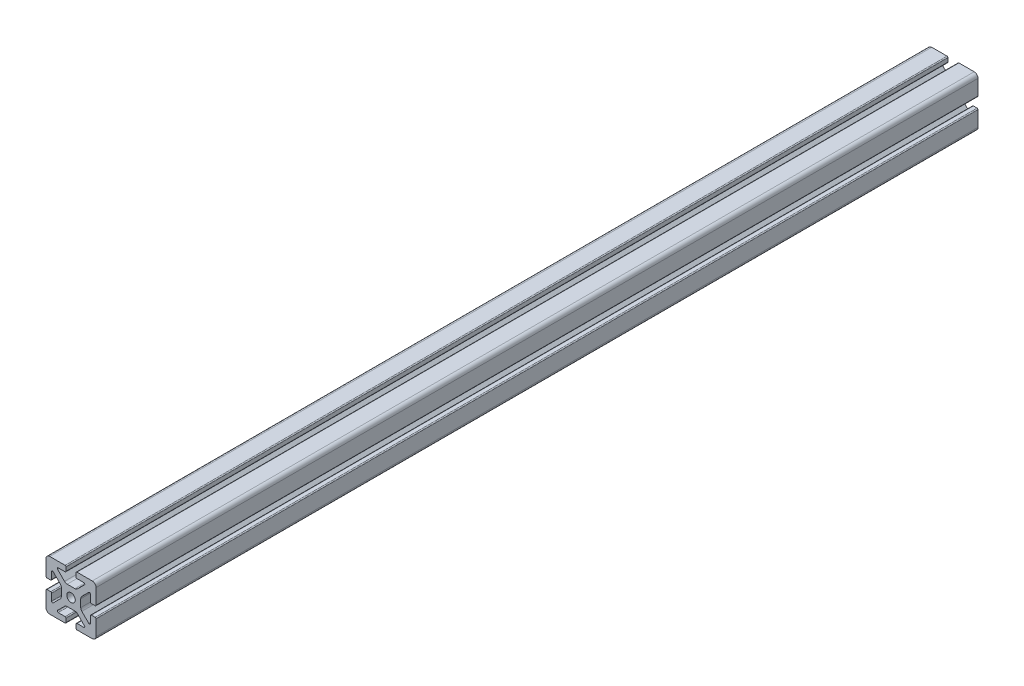
from build123d import *

# Parameters (mm, degrees)
SKETCH1_R           = 3.4036
BOSS_EXTRUDE1_DEPTH = 352.5


with BuildPart() as part:
    # Sketch1 → Boss-Extrude1 (new body, symmetric)
    with BuildSketch(Plane.XY):
        with BuildLine():
            Line((-20, 16.952), (-20, 4.7625))
            ThreePointArc((-20, 4.7625), (-19.776815367, 4.223684633), (-19.238, 4.0005))
            Line((-19.238, 4.0005), (-16.2662, 4.0005))
            ThreePointArc((-16.2662, 4.0005), (-15.727384633, 4.223684633), (-15.5042, 4.7625))
            Line((-15.5042, 4.7625), (-15.5042, 10.2235))
            ThreePointArc((-15.5042, 10.2235), (-15.033804775, 10.927496204), (-14.203384633, 10.762315367))
            Line((-14.203384633, 10.762315367), (-8.635059555, 5.19399029))
            ThreePointArc((-8.635059555, 5.19399029), (-7.985348265, 4.221628629), (-7.7572, 3.074649845))
            Line((-7.7572, 3.074649845), (-7.7572, -3.074649845))
            ThreePointArc((-7.7572, -3.074649845), (-7.985348265, -4.221628629), (-8.635059555, -5.19399029))
            Line((-8.635059555, -5.19399029), (-14.203384633, -10.762315367))
            ThreePointArc((-14.203384633, -10.762315367), (-15.033804775, -10.927496204), (-15.5042, -10.2235))
            Line((-15.5042, -10.2235), (-15.5042, -4.7625))
            ThreePointArc((-15.5042, -4.7625), (-15.727384633, -4.223684633), (-16.2662, -4.0005))
            Line((-16.2662, -4.0005), (-19.238, -4.0005))
            ThreePointArc((-19.238, -4.0005), (-19.776815367, -4.223684633), (-20, -4.7625))
            Line((-20, -4.7625), (-20, -16.952))
            ThreePointArc((-20, -16.952), (-19.107261469, -19.107261469), (-16.952, -20))
            Line((-16.952, -20), (-4.7625, -20))
            ThreePointArc((-4.7625, -20), (-4.223684633, -19.776815367), (-4.0005, -19.238))
            Line((-4.0005, -19.238), (-4.0005, -16.2662))
            ThreePointArc((-4.0005, -16.2662), (-4.223684633, -15.727384633), (-4.7625, -15.5042))
            Line((-4.7625, -15.5042), (-10.2235, -15.5042))
            ThreePointArc((-10.2235, -15.5042), (-10.927496204, -15.033804775), (-10.762315367, -14.203384633))
            Line((-10.762315367, -14.203384633), (-5.19399029, -8.635059555))
            ThreePointArc((-5.19399029, -8.635059555), (-4.221628629, -7.985348265), (-3.074649845, -7.7572))
            Line((-3.074649845, -7.7572), (3.074649845, -7.7572))
            ThreePointArc((3.074649845, -7.7572), (4.221628629, -7.985348265), (5.19399029, -8.635059555))
            Line((5.19399029, -8.635059555), (10.762315367, -14.203384633))
            ThreePointArc((10.762315367, -14.203384633), (10.927496204, -15.033804775), (10.2235, -15.5042))
            Line((10.2235, -15.5042), (4.7625, -15.5042))
            ThreePointArc((4.7625, -15.5042), (4.223684633, -15.727384633), (4.0005, -16.2662))
            Line((4.0005, -16.2662), (4.0005, -19.238))
            ThreePointArc((4.0005, -19.238), (4.223684633, -19.776815367), (4.7625, -20))
            Line((4.7625, -20), (16.952, -20))
            ThreePointArc((16.952, -20), (19.107261469, -19.107261469), (20, -16.952))
            Line((20, -16.952), (20, -4.7625))
            ThreePointArc((20, -4.7625), (19.776815367, -4.223684633), (19.238, -4.0005))
            Line((19.238, -4.0005), (16.2662, -4.0005))
            ThreePointArc((16.2662, -4.0005), (15.727384633, -4.223684633), (15.5042, -4.7625))
            Line((15.5042, -4.7625), (15.5042, -10.2235))
            ThreePointArc((15.5042, -10.2235), (15.033804775, -10.927496204), (14.203384633, -10.762315367))
            Line((14.203384633, -10.762315367), (8.635059555, -5.19399029))
            ThreePointArc((8.635059555, -5.19399029), (7.985348265, -4.221628629), (7.7572, -3.074649845))
            Line((7.7572, -3.074649845), (7.7572, 3.074649845))
            ThreePointArc((7.7572, 3.074649845), (7.985348265, 4.221628629), (8.635059555, 5.19399029))
            Line((8.635059555, 5.19399029), (14.203384633, 10.762315367))
            ThreePointArc((14.203384633, 10.762315367), (15.033804775, 10.927496204), (15.5042, 10.2235))
            Line((15.5042, 10.2235), (15.5042, 4.7625))
            ThreePointArc((15.5042, 4.7625), (15.727384633, 4.223684633), (16.2662, 4.0005))
            Line((16.2662, 4.0005), (19.238, 4.0005))
            ThreePointArc((19.238, 4.0005), (19.776815367, 4.223684633), (20, 4.7625))
            Line((20, 4.7625), (20, 16.952))
            ThreePointArc((20, 16.952), (19.107261469, 19.107261469), (16.952, 20))
            Line((16.952, 20), (4.7625, 20))
            ThreePointArc((4.7625, 20), (4.223684633, 19.776815367), (4.0005, 19.238))
            Line((4.0005, 19.238), (4.0005, 16.2662))
            ThreePointArc((4.0005, 16.2662), (4.223684633, 15.727384633), (4.7625, 15.5042))
            Line((4.7625, 15.5042), (10.2235, 15.5042))
            ThreePointArc((10.2235, 15.5042), (10.927496204, 15.033804775), (10.762315367, 14.203384633))
            Line((10.762315367, 14.203384633), (5.19399029, 8.635059555))
            ThreePointArc((5.19399029, 8.635059555), (4.221628629, 7.985348265), (3.074649845, 7.7572))
            Line((3.074649845, 7.7572), (-3.074649845, 7.7572))
            ThreePointArc((-3.074649845, 7.7572), (-4.221628629, 7.985348265), (-5.19399029, 8.635059555))
            Line((-5.19399029, 8.635059555), (-10.762315367, 14.203384633))
            ThreePointArc((-10.762315367, 14.203384633), (-10.927496204, 15.033804775), (-10.2235, 15.5042))
            Line((-10.2235, 15.5042), (-4.7625, 15.5042))
            ThreePointArc((-4.7625, 15.5042), (-4.223684633, 15.727384633), (-4.0005, 16.2662))
            Line((-4.0005, 16.2662), (-4.0005, 19.238))
            ThreePointArc((-4.0005, 19.238), (-4.223684633, 19.776815367), (-4.7625, 20))
            Line((-4.7625, 20), (-16.952, 20))
            ThreePointArc((-16.952, 20), (-19.107261469, 19.107261469), (-20, 16.952))
        make_face()
        Circle(SKETCH1_R, mode=Mode.SUBTRACT)
    extrude(amount=BOSS_EXTRUDE1_DEPTH, both=True)


solid = part.part
